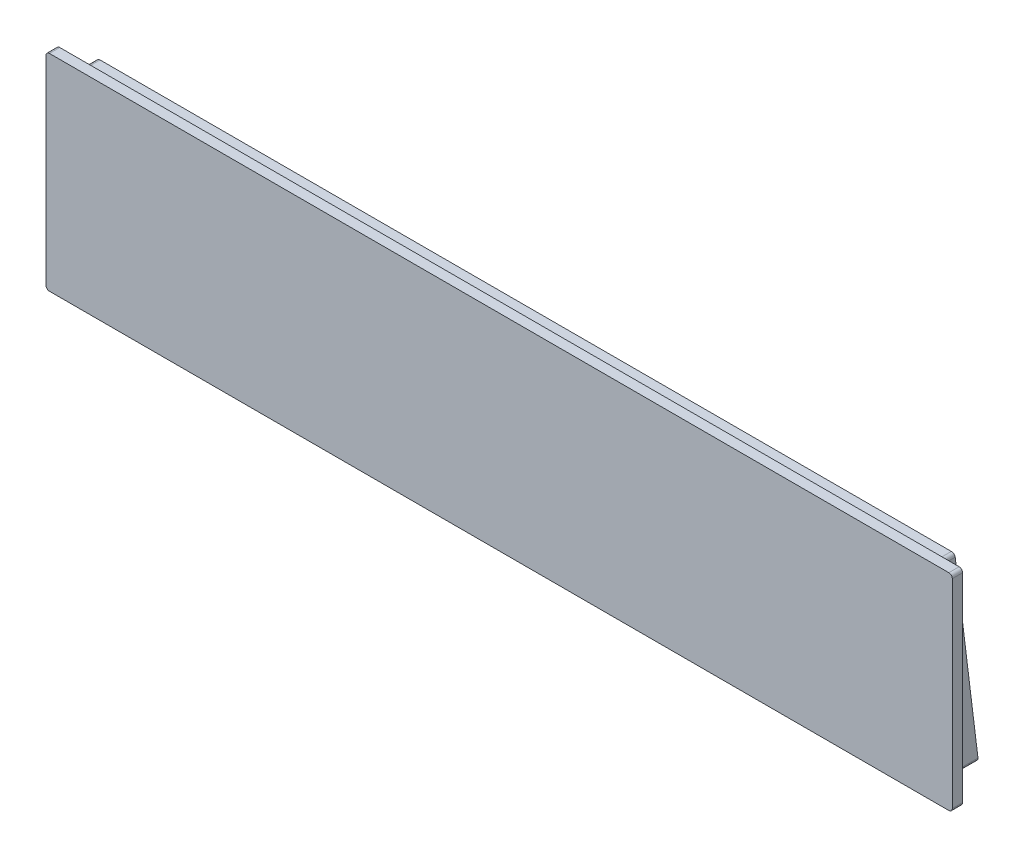
from build123d import *

# Parameters (mm, degrees)
SKETCH1_W                = 264
SKETCH1_H                = 60
BOSS_EXTRUDE1_DEPTH      = 3
BOSS_EXTRUDE2_DEPTH      = 125
BOSS_EXTRUDE2_DEPTH_BACK = 125
FILLET1_R                = 1


with BuildPart() as part:
    # Sketch1 → Boss-Extrude1 (new body)
    with BuildSketch(Plane.XY):
        Rectangle(SKETCH1_W, SKETCH1_H)
    extrude(amount=BOSS_EXTRUDE1_DEPTH)

    # Sketch2 → Boss-Extrude2 (add, two sides)
    with BuildSketch(Plane(origin=(0, 0, 0), x_dir=(0, 0, -1), z_dir=(1, 0, 0))) as boss_extrude2_sk:
        Polygon((0, 28), (4.73, 28), (11.605935411, -28), (0, -28), align=None)
    extrude(amount=BOSS_EXTRUDE2_DEPTH)
    extrude(boss_extrude2_sk.sketch, amount=-BOSS_EXTRUDE2_DEPTH_BACK)

    # Fillet1
    fillet1_edges = [part.edges().sort_by_distance(p)[0] for p in [
        (125, 28, -2.365),
        (125, -28, -5.802967705),
        (-125, 28, -2.365),
        (-125, -28, -5.802967705),
        (-132, 30, 1.5),
        (132, 30, 1.5),
        (132, -30, 1.5),
        (-132, -30, 1.5),
    ]]
    fillet(fillet1_edges, radius=FILLET1_R)


solid = part.part
